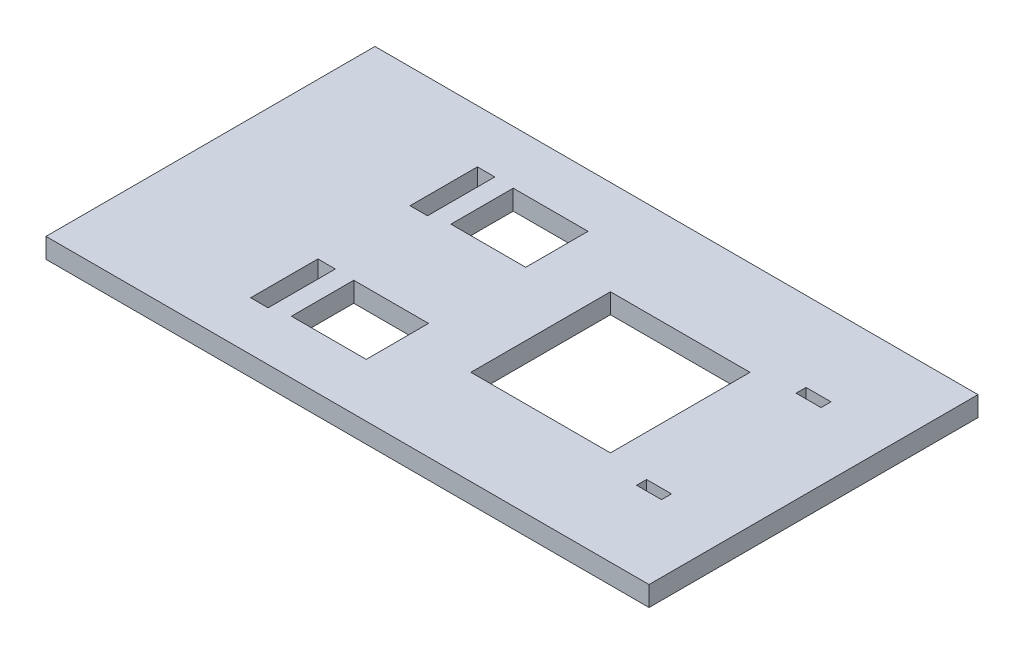
from build123d import *

# Parameters (mm, degrees)
SKETCH1_W           = 121
SKETCH1_H           = 66
BOSS_EXTRUDE1_DEPTH = 4
SKETCH2_W           = 28
SKETCH2_H           = 28
SKETCH2_W_2         = 15
SKETCH2_H_2         = 12.5
CUT_EXTRUDE1_DEPTH  = 5
SKETCH3_W           = 5
SKETCH3_H           = 2
CUT_EXTRUDE2_DEPTH  = 5
SKETCH4_W           = 3.5
SKETCH4_H           = 13.5
CUT_EXTRUDE3_DEPTH  = 5


with BuildPart() as part:
    # Sketch1 → Boss-Extrude1 (new body)
    with BuildSketch(Plane(origin=(0, 0, 0), x_dir=(1, 0, 0), z_dir=(0, 1, 0))):
        with Locations((60.5, -33)):
            Rectangle(SKETCH1_W, SKETCH1_H)
    extrude(amount=BOSS_EXTRUDE1_DEPTH)

    # Sketch2 → Cut-Extrude1 (cut, through all)
    with BuildSketch(Plane(origin=(0, 4, 0), x_dir=(1, 0, 0), z_dir=(0, 1, 0))):
        with Locations((80.25, -33)):
            Rectangle(SKETCH2_W, SKETCH2_H)
        with Locations((46, -17)):
            Rectangle(SKETCH2_W_2, SKETCH2_H_2)
        with Locations((46, -49)):
            Rectangle(SKETCH2_W_2, SKETCH2_H_2)
    extrude(amount=-CUT_EXTRUDE1_DEPTH, mode=Mode.SUBTRACT)

    # Sketch3 → Cut-Extrude2 (cut, through all)
    with BuildSketch(Plane.XZ):
        with Locations((105, 49)):
            Rectangle(SKETCH3_W, SKETCH3_H)
        with Locations((105, 17)):
            Rectangle(SKETCH3_W, SKETCH3_H)
    extrude(amount=-CUT_EXTRUDE2_DEPTH, mode=Mode.SUBTRACT)

    # Sketch4 → Cut-Extrude3 (cut, through all)
    with BuildSketch(Plane(origin=(0, 4, 0), x_dir=(1, 0, 0), z_dir=(0, 1, 0))):
        with Locations((32.95, -49.395895757)):
            Rectangle(SKETCH4_W, SKETCH4_H)
        with Locations((32.95, -17.399625311)):
            Rectangle(SKETCH4_W, SKETCH4_H)
    extrude(amount=-CUT_EXTRUDE3_DEPTH, mode=Mode.SUBTRACT)


solid = part.part
